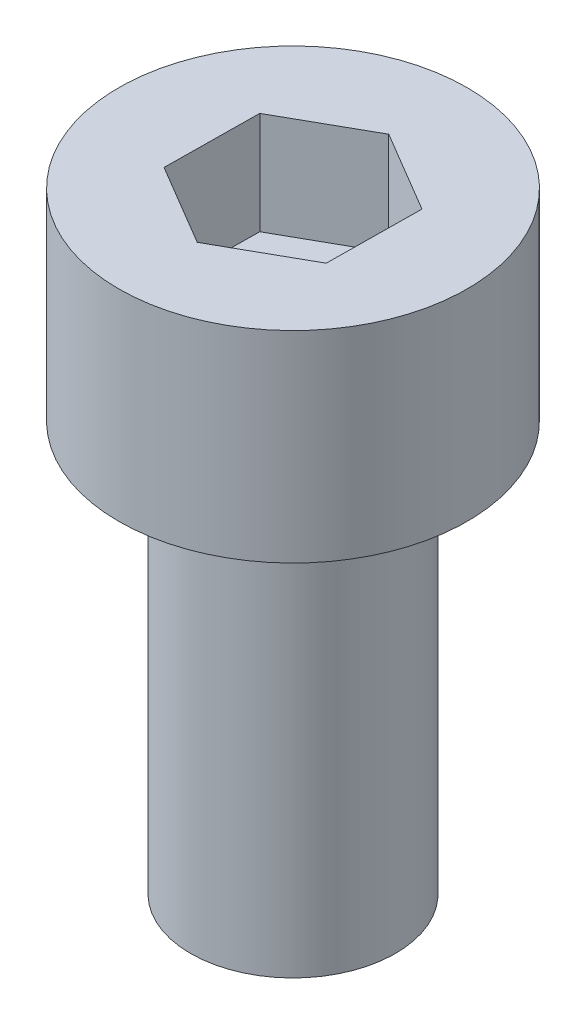
from build123d import *

# Parameters (mm, degrees)
SKETCH_1_R          = 2.5
EXTRUDE_1_DEPTH     = 10
SKETCH_2_R          = 4.25
EXTRUDE_2_DEPTH     = 4.91
CUT_EXTRUDE_1_DEPTH = 2.5


with BuildPart() as part:
    # 草图1 → 凸台-拉伸1 (new body)
    with BuildSketch(Plane(origin=(0, 0, 0), x_dir=(1, 0, 0), z_dir=(0, 1, 0))):
        Circle(SKETCH_1_R)
    extrude(amount=EXTRUDE_1_DEPTH)

    # 草图2 → 凸台-拉伸2 (add)
    with BuildSketch(Plane(origin=(0, 10, 0), x_dir=(1, 0, 0), z_dir=(0, 1, 0))):
        Circle(SKETCH_2_R)
    extrude(amount=EXTRUDE_2_DEPTH)

    # 草图3 → 切除-拉伸1 (cut)
    with BuildSketch(Plane(origin=(0, 14.91, 0), x_dir=(1, 0, 0), z_dir=(0, 1, 0))):
        Polygon((1.987239819, -1.176525067), (2.012520506, 1.132737633), (0.025280687, 2.309262701), (-1.987239819, 1.176525067), (-2.012520506, -1.132737633), (-0.025280687, -2.309262701), align=None)
    extrude(amount=-CUT_EXTRUDE_1_DEPTH, mode=Mode.SUBTRACT)


solid = part.part
